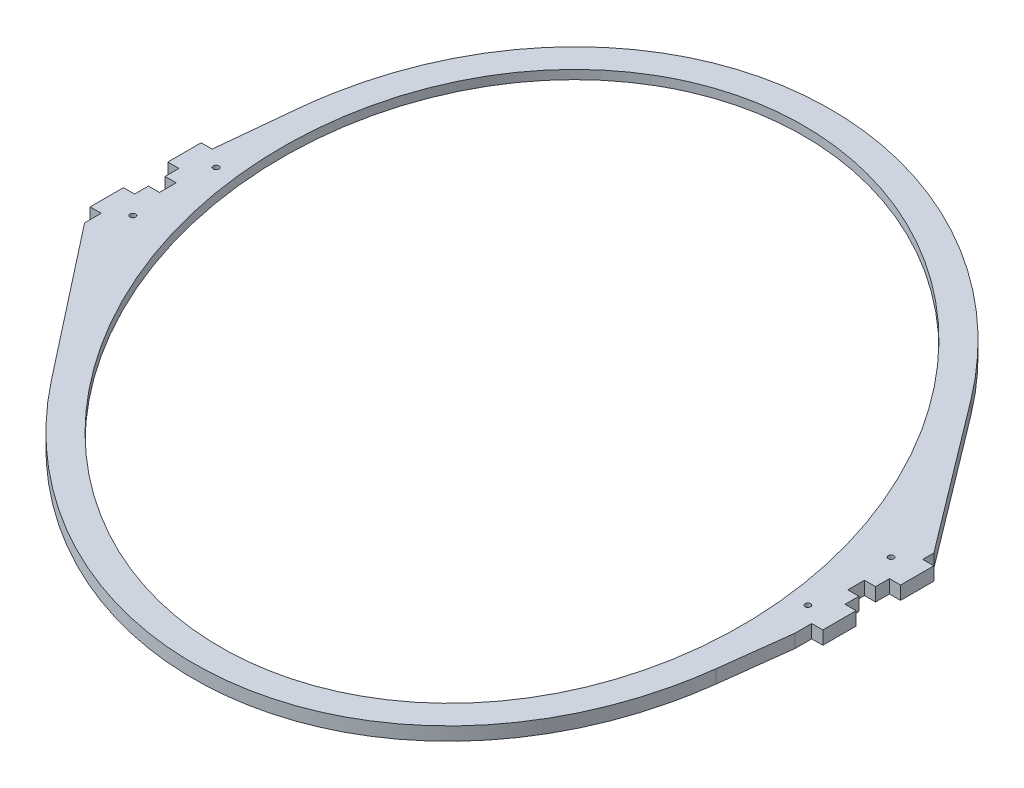
from build123d import *

# Parameters (mm, degrees)
SKETCH1_RX                   = 355
SKETCH1_RY                   = 265
BOSS_EXTRUDE1_DEPTH          = 12
SKETCH2_W                    = 10
SKETCH2_H                    = 15
CUT_EXTRUDE1_DEPTH           = 12
F_5_0_5_DIAMETER_HOLE2_D     = 5
F_5_0_5_DIAMETER_HOLE2_DEPTH = 25
F_5_0_5_DIAMETER_HOLE2_TIP   = 1.502151548
SKETCH9_RX                   = 365
SKETCH9_RY                   = 275
CUT_EXTRUDE4_DEPTH           = 4


with BuildPart() as part:
    # Sketch1 → Boss-Extrude1 (new body)
    with BuildSketch(Plane(origin=(0, 0, 0), x_dir=(1, 0, 0), z_dir=(0, 1, 0))):
        with BuildLine():
            Line((-320, 50), (-320, 51))
            Line((-320, 51), (-313.091302172, 120.09271769))
            add(Edge.make_bspline(
                [(217.547896668, 195.738545202), (-244.337364097, 807.689215884), (-313.091302172, 120.09271769)],
                knots=[4.872921291, 4.872921291, 4.872921291, 7.098478155, 7.098478155, 7.098478155], degree=2, weights=[1, 0.442171166, 1]))
            Line((217.547896668, 195.738545202), (320, 60))
            Line((320, 60), (320, 50))
            Line((320, 50), (330, 50))
            Line((330, 50), (330, 20))
            Line((330, 20), (320, 20))
            Line((320, 20), (320, 0))
            Line((320, 0), (320, -20))
            Line((320, -20), (330, -20))
            Line((330, -20), (330, -50))
            Line((330, -50), (320, -50))
            Line((320, -50), (320, -65))
            Line((320, -65), (312.170159719, -128.33520269))
            add(Edge.make_bspline(
                [(-212.28214963, -202.588475219), (232.721291269, -770.993291043), (312.170159719, -128.33520269)],
                knots=[1.754206291, 1.754206291, 1.754206291, 3.932461359, 3.932461359, 3.932461359], degree=2, weights=[1, 0.463258742, 1]))
            Line((-212.28214963, -202.588475219), (-320, -65))
            Line((-320, -65), (-320, -50))
            Line((-320, -50), (-330, -50))
            Line((-330, -50), (-330, -20))
            Line((-330, -20), (-320, -20))
            Line((-320, -20), (-320, 0))
            Line((-320, 0), (-320, 20))
            Line((-320, 20), (-330, 20))
            Line((-330, 20), (-330, 50))
            Line((-330, 50), (-320, 50))
        make_face()
        with Locations(Location((0, 0), (0, 0, 120))):
            Ellipse(SKETCH1_RX, SKETCH1_RY, mode=Mode.SUBTRACT)
    extrude(amount=BOSS_EXTRUDE1_DEPTH)

    # Sketch2 → Cut-Extrude1 (cut)
    with BuildSketch(Plane(origin=(0, 12, 0), x_dir=(1, 0, 0), z_dir=(0, 1, 0))):
        with Locations((315, 0)):
            Rectangle(SKETCH2_W, SKETCH2_H)
        with Locations((-315, 0)):
            Rectangle(SKETCH2_W, SKETCH2_H)
    extrude(amount=-CUT_EXTRUDE1_DEPTH, mode=Mode.SUBTRACT)

    # Ø5.0 (5) Diameter Hole2
    with Locations(Plane(origin=(0, 12, 0), x_dir=(1, 0, 0), z_dir=(0, 1, 0))):
        with Locations((304, 37.5), (304, -37.5), (-304, -37.5), (-304, 37.5)):
            Hole(F_5_0_5_DIAMETER_HOLE2_D / 2, depth=F_5_0_5_DIAMETER_HOLE2_DEPTH)
            with Locations((0, 0, -(F_5_0_5_DIAMETER_HOLE2_DEPTH + F_5_0_5_DIAMETER_HOLE2_TIP / 2))):  # 118° drill point
                Cone(0, F_5_0_5_DIAMETER_HOLE2_D / 2, F_5_0_5_DIAMETER_HOLE2_TIP, mode=Mode.SUBTRACT)

    # Sketch9 → Cut-Extrude4 (cut)
    with BuildSketch(Plane.XZ):
        with Locations(Location((0, 0), (0, 0, -119.999999993))):
            Ellipse(SKETCH9_RX, SKETCH9_RY)
    extrude(amount=-CUT_EXTRUDE4_DEPTH, mode=Mode.SUBTRACT)


solid = part.part
